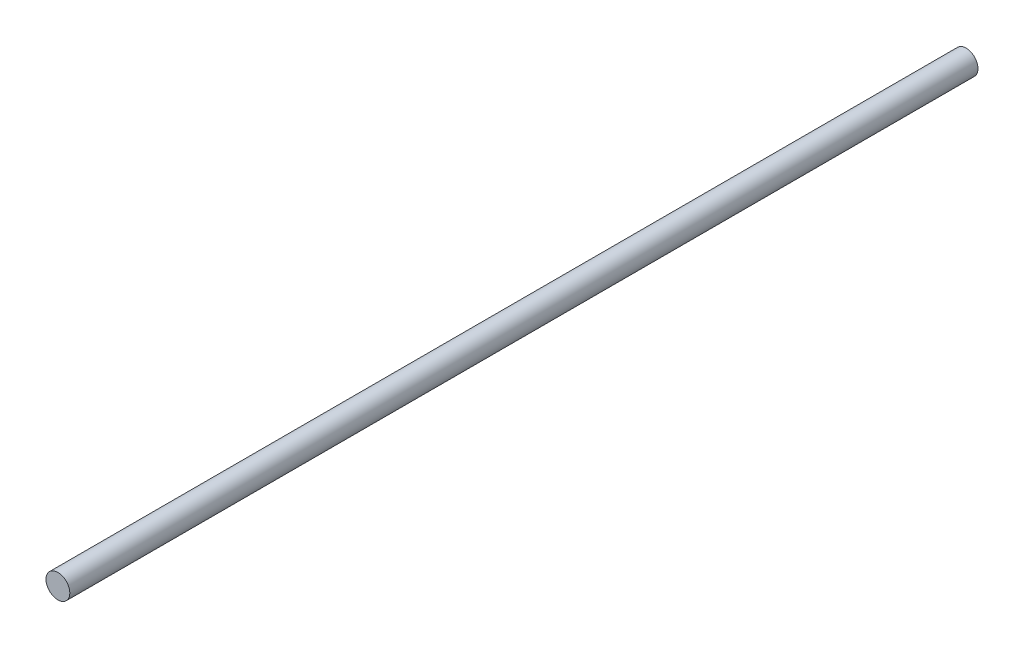
from build123d import *

# Parameters (mm, degrees)
ESBO_O1_R                = 4
RESSALTO_EXTRUS_O1_DEPTH = 305


with BuildPart() as part:
    # Esboço1 → Ressalto-extrusão1 (new body)
    with BuildSketch(Plane.XY):
        with Locations((-48.875298619, 81.407156415)):
            Circle(ESBO_O1_R)
    extrude(amount=RESSALTO_EXTRUS_O1_DEPTH)


solid = part.part
